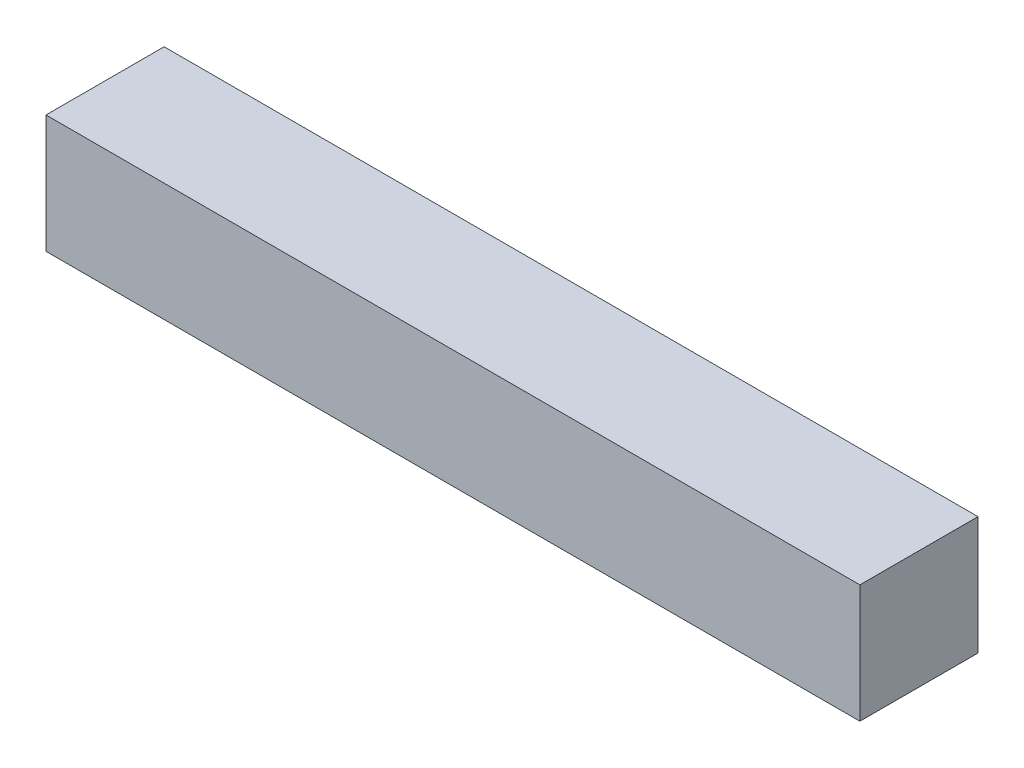
from build123d import *

# Parameters (mm, degrees)
SKETCH1_3_W         = 350
SKETCH1_3_H         = 50.8
BOSS_EXTRUDE2_DEPTH = 50.8


with BuildPart() as part:
    # Sketch1_3 → Boss-Extrude2 (new body)
    with BuildSketch(Plane.XY):
        Rectangle(SKETCH1_3_W, SKETCH1_3_H)
    extrude(amount=BOSS_EXTRUDE2_DEPTH)


solid = part.part
